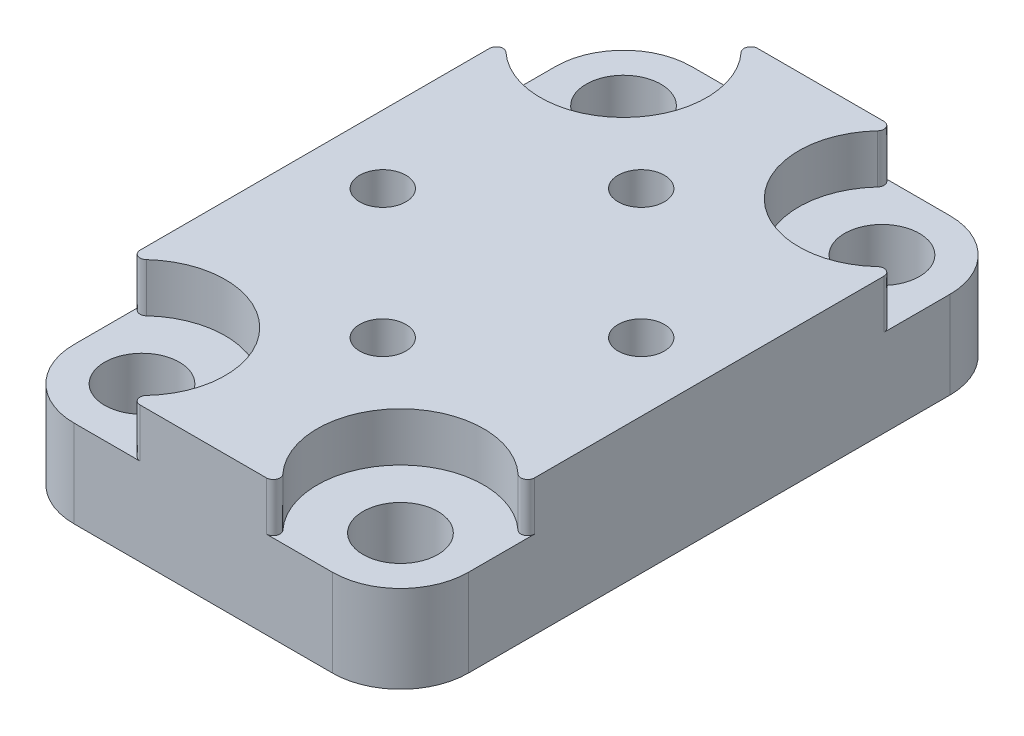
from build123d import *

# Parameters (mm, degrees)
SKETCH1_W                                       = 29
SKETCH1_H                                       = 45.4
BOSS_EXTRUDE1_DEPTH                             = 10
CBORE_FOR_M5_HEX_HEAD_BOLT1_D                   = 5.5
CBORE_FOR_M5_HEX_HEAD_BOLT1_DEPTH               = 15
CBORE_FOR_M5_HEX_HEAD_BOLT1_CBORE_D             = 12.24
CBORE_FOR_M5_HEX_HEAD_BOLT1_CBORE_DEPTH         = 3.58
CBORE_FOR_M5_HEX_HEAD_BOLT1_TIP                 = 1.652366702
CSK_FOR_M3_FLAT_HEAD_MACHINE_SCREW1_D           = 3.4
CSK_FOR_M3_FLAT_HEAD_MACHINE_SCREW1_CSINK_D     = 6.3
CSK_FOR_M3_FLAT_HEAD_MACHINE_SCREW1_CSINK_ANGLE = 90
FILLET1_R                                       = 5
FILLET2_R                                       = 0.5


with BuildPart() as part:
    # Sketch1 → Boss-Extrude1 (new body)
    with BuildSketch(Plane(origin=(0, 0, 0), x_dir=(1, 0, 0), z_dir=(0, 1, 0))):
        Rectangle(SKETCH1_W, SKETCH1_H)
    extrude(amount=-BOSS_EXTRUDE1_DEPTH)

    # CBORE for M5 Hex Head Bolt1
    with Locations(Plane(origin=(0, 0, 0), x_dir=(1, 0, 0), z_dir=(0, 1, 0))):
        with Locations((-9.5, 17.7), (9.5, 17.7), (9.5, -17.7), (-9.5, -17.7)):
            CounterBoreHole(CBORE_FOR_M5_HEX_HEAD_BOLT1_D / 2, CBORE_FOR_M5_HEX_HEAD_BOLT1_CBORE_D / 2, CBORE_FOR_M5_HEX_HEAD_BOLT1_CBORE_DEPTH, depth=CBORE_FOR_M5_HEX_HEAD_BOLT1_DEPTH)
            with Locations((0, 0, -(CBORE_FOR_M5_HEX_HEAD_BOLT1_DEPTH + CBORE_FOR_M5_HEX_HEAD_BOLT1_TIP / 2))):  # 118° drill point
                Cone(0, CBORE_FOR_M5_HEX_HEAD_BOLT1_D / 2, CBORE_FOR_M5_HEX_HEAD_BOLT1_TIP, mode=Mode.SUBTRACT)

    # CSK for M3 Flat Head Machine Screw1 (through all)
    with Locations(Plane(origin=(0, -10, 0), x_dir=(-1, 0, 0), z_dir=(0, -1, 0))):
        with Locations((-9.5, 0), (0, 9.5), (9.5, 0), (0, -9.5)):
            CounterSinkHole(CSK_FOR_M3_FLAT_HEAD_MACHINE_SCREW1_D / 2, CSK_FOR_M3_FLAT_HEAD_MACHINE_SCREW1_CSINK_D / 2, counter_sink_angle=CSK_FOR_M3_FLAT_HEAD_MACHINE_SCREW1_CSINK_ANGLE)

    # Fillet1
    fillet1_edges = [part.edges().sort_by_distance(p)[0] for p in [
        (-14.5, -5, -22.7),
        (14.5, -5, -22.7),
        (14.5, -5, 22.7),
        (-14.5, -5, 22.7),
    ]]
    fillet(fillet1_edges, radius=FILLET1_R)

    # Fillet2
    fillet2_edges = [part.edges().sort_by_distance(p)[0] for p in [
        (-5.9709208, -1.79, 22.7),
        (-14.5, -1.79, 14.1709208),
        (14.5, -1.79, 14.1709208),
        (5.9709208, -1.79, 22.7),
        (14.5, -1.79, -14.1709208),
        (5.9709208, -1.79, -22.7),
        (-5.9709208, -1.79, -22.7),
        (-14.5, -1.79, -14.1709208),
    ]]
    fillet(fillet2_edges, radius=FILLET2_R)


solid = part.part
